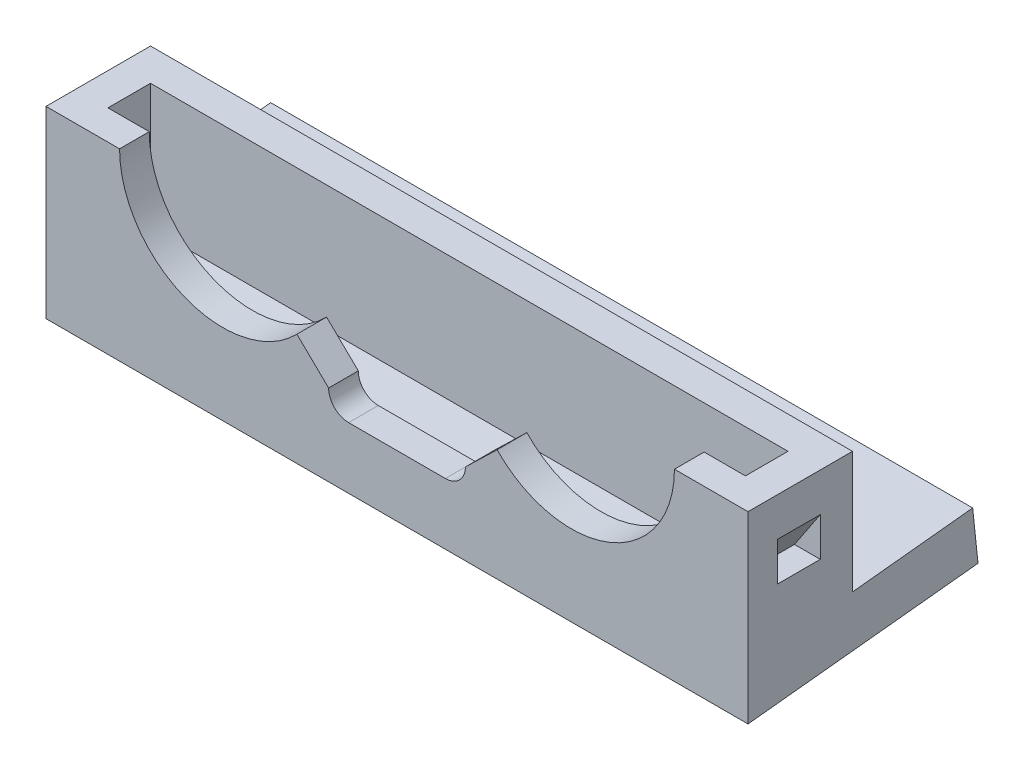
from build123d import *

# Parameters (mm, degrees)
SKETCH2_W           = 54.4
SKETCH2_H           = 16
BOSS_EXTRUDE1_DEPTH = 4
SKETCH3_W           = 2.3
SKETCH3_H           = 24
BOSS_EXTRUDE2_DEPTH = 54.4
SKETCH4_R           = 2.3
CUT_EXTRUDE1_DEPTH  = 45
CUT_EXTRUDE3_DEPTH  = 10
SKETCH5_R           = 8
CUT_EXTRUDE2_DEPTH  = 10
CUT_EXTRUDE4_DEPTH  = 10
SKETCH8_W           = 2.5
SKETCH8_H           = 10.25
BOSS_EXTRUDE3_DEPTH = 54.4
SKETCH9_W           = 2.5
SKETCH9_H           = 3.3
BOSS_EXTRUDE4_DEPTH = 10.25
CUT_EXTRUDE5_DEPTH  = 3.3
SKETCH11_W          = 54.4
SKETCH11_H          = 10.2
CUT_EXTRUDE6_DEPTH  = 10
BOSS_EXTRUDE5_DEPTH = 54.4
CUT_EXTRUDE7_DEPTH  = 54.4
SKETCH14_R          = 2.3
CUT_EXTRUDE8_DEPTH  = 54.4


with BuildPart() as part:
    # Sketch2 → Boss-Extrude1 (new body)
    with BuildSketch(Plane(origin=(0, 0, 0), x_dir=(1, 0, 0), z_dir=(0, 1, 0))):
        Rectangle(SKETCH2_W, SKETCH2_H)
    extrude(amount=BOSS_EXTRUDE1_DEPTH)

    # Sketch3 → Boss-Extrude2 (add)
    with BuildSketch(Plane(origin=(27.2, 0, 0), x_dir=(0, 0, -1), z_dir=(1, 0, 0))):
        with Locations((-9.15, 12)):
            Rectangle(SKETCH3_W, SKETCH3_H)
    extrude(amount=-BOSS_EXTRUDE2_DEPTH)

    # Sketch4 → Cut-Extrude1 (cut)
    with BuildSketch(Plane(origin=(0, 4, 0), x_dir=(1, 0, 0), z_dir=(0, 1, 0))):
        with Locations((-13.5, 2.5)):
            Circle(SKETCH4_R)
        with Locations((13.5, 2.5)):
            Circle(SKETCH4_R)
    extrude(amount=-CUT_EXTRUDE1_DEPTH, mode=Mode.SUBTRACT)

    # Sketch6 → Cut-Extrude3 (cut)
    with BuildSketch(Plane.XY.offset(10.3)):
        with BuildLine():
            Line((-3.75, 7.85), (3.75, 7.85))
            ThreePointArc((3.75, 7.85), (5.3, 6.3), (3.75, 4.75))
            Line((3.75, 4.75), (-3.75, 4.75))
            ThreePointArc((-3.75, 4.75), (-5.3, 6.3), (-3.75, 7.85))
        make_face()
    extrude(amount=-CUT_EXTRUDE3_DEPTH, mode=Mode.SUBTRACT)

    # Sketch5 → Cut-Extrude2 (cut)
    with BuildSketch(Plane.XY.offset(10.3)):
        with Locations((-13.5, 14.25)):
            Circle(SKETCH5_R)
        with Locations((13.5, 14.25)):
            Circle(SKETCH5_R)
    extrude(amount=-CUT_EXTRUDE2_DEPTH, mode=Mode.SUBTRACT)

    # Sketch7 → Cut-Extrude4 (cut)
    with BuildSketch(Plane.XY.offset(10.3)):
        Polygon((-35.24269893, 14.25), (-13.5, 14.25), (-5.3, 6.3), (0, 6.5), (5.3, 6.3), (13.5, 14.25), (21.5, 14.25), (36.006358293, 14.25), (36.006358293, 27.887641337), (-35.24269893, 27.887641337), align=None)
    extrude(amount=-CUT_EXTRUDE4_DEPTH, mode=Mode.SUBTRACT)

    # Sketch8 → Boss-Extrude3 (add)
    with BuildSketch(Plane(origin=(27.2, 0, 0), x_dir=(0, 0, -1), z_dir=(1, 0, 0))):
        with Locations((-3.45, 9.125)):
            Rectangle(SKETCH8_W, SKETCH8_H)
    extrude(amount=-BOSS_EXTRUDE3_DEPTH)

    # Sketch9 → Boss-Extrude4 (add)
    with BuildSketch(Plane(origin=(0, 4, 0), x_dir=(1, 0, 0), z_dir=(0, 1, 0))):
        with Locations((-25.95, -6.35)):
            Rectangle(SKETCH9_W, SKETCH9_H)
        with Locations((25.95, -6.35)):
            Rectangle(SKETCH9_W, SKETCH9_H)
    extrude(amount=BOSS_EXTRUDE4_DEPTH)

    # Sketch10 → Cut-Extrude5 (cut)
    with BuildSketch(Plane.XY.offset(4.7)):
        Polygon((-27.2, 8.25), (-25.2, 8.25), (-27.2, 11.25), align=None)
        Polygon((27.2, 11.25), (27.2, 8.25), (25.2, 8.25), align=None)
    extrude(amount=CUT_EXTRUDE5_DEPTH, mode=Mode.SUBTRACT)

    # Sketch11 → Cut-Extrude6 (cut)
    with BuildSketch(Plane(origin=(0, 4, 0), x_dir=(1, 0, 0), z_dir=(0, 1, 0))):
        with Locations((0, 2.9)):
            Rectangle(SKETCH11_W, SKETCH11_H)
    extrude(amount=-CUT_EXTRUDE6_DEPTH, mode=Mode.SUBTRACT)

    # Sketch12 → Boss-Extrude5 (add)
    with BuildSketch(Plane.ZY.offset(27.2)):
        Polygon((10.3, 0), (-7.522416627, 1.87321147), (-7.110333074, 5.793924586), (10.3, 3.964024842), align=None)
    extrude(amount=-BOSS_EXTRUDE5_DEPTH)

    # Sketch13 → Cut-Extrude7 (cut)
    with BuildSketch(Plane(origin=(27.2, 0, 0), x_dir=(0, 0, -1), z_dir=(1, 0, 0))):
        Polygon((-2.2, 0.851344306), (-10.3, 0), (-2.2, 0), align=None)
    extrude(amount=-CUT_EXTRUDE7_DEPTH, mode=Mode.SUBTRACT)

    # Sketch14 → Cut-Extrude8 (cut)
    with BuildSketch(Plane(origin=(0, 4.991458323, 0.52462341), x_dir=(1, 0, 0), z_dir=(0, 0.994521895, 0.104528463))):
        with Locations((-13.5, 2.904418591)):
            Circle(SKETCH14_R)
        with Locations((13.5, 2.904418591)):
            Circle(SKETCH14_R)
    extrude(amount=-CUT_EXTRUDE8_DEPTH, mode=Mode.SUBTRACT)


solid = part.part
